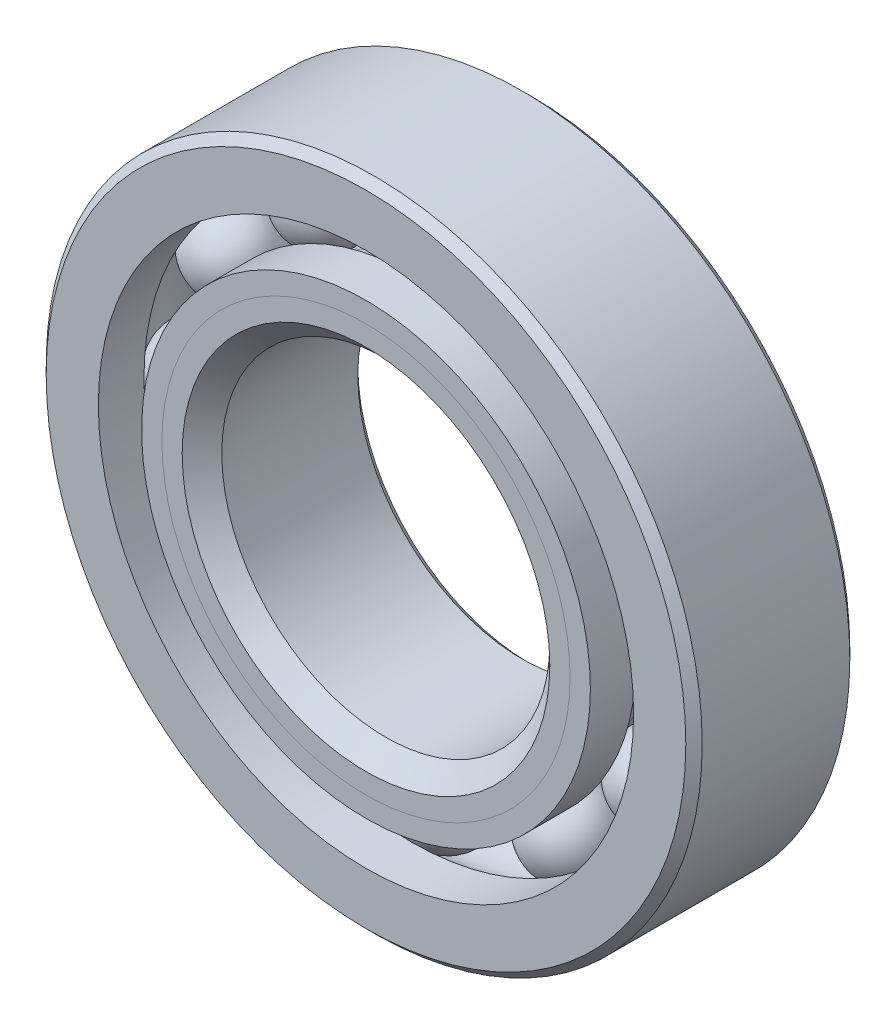
from build123d import *

# Parameters (mm, degrees)
CIRPATTERN1_COUNT = 12


with BuildPart() as part:
    # Sketch1 → Revolve1 (revolve)
    with BuildSketch(Plane(origin=(0, 0, 0), x_dir=(0, 0, -1), z_dir=(1, 0, 0))):
        with BuildLine():
            Line((1.42875, 6.35), (-1.42875, 6.35))
            Line((-1.42875, 6.35), (-1.5875, 6.19125))
            Line((-1.5875, 6.19125), (-1.5875, 5.181181319))
            Line((-1.5875, 5.181181319), (-0.705555556, 5.181181319))
            ThreePointArc((-0.705555556, 5.181181319), (0, 5.582928357), (0.705555556, 5.181181319))
            Line((0.705555556, 5.181181319), (1.5875, 5.181181319))
            Line((1.5875, 5.181181319), (1.5875, 6.19125))
            Line((1.5875, 6.19125), (1.42875, 6.35))
        make_face()
    revolve(axis=Axis((0, 0, 1.5875), (0, 0, -1)))


with BuildPart() as body_2:
    # Sketch2 → Revolve2 (revolve)
    with BuildSketch(Plane(origin=(0, 0, 0), x_dir=(0, 0, -1), z_dir=(1, 0, 0))):
        with BuildLine():
            Line((-1.5875, 4.343818681), (-0.705555556, 4.343818681))
            ThreePointArc((-0.705555556, 4.343818681), (-0.405958534, 4.049548138), (0, 3.942071643))
            Line((0, 3.942071643), (0, 3.558535822))
            Line((0, 3.558535822), (-1.19485857, 3.558535822))
            Line((-1.19485857, 3.558535822), (-1.5875, 3.951177251))
            Line((-1.5875, 3.951177251), (-1.5875, 4.343818681))
        make_face()
    revolve(axis=Axis((0, 0, 1.5875), (0, 0, -1)))


with BuildPart() as body_3:
    # Sketch3 → Revolve3 (revolve)
    with BuildSketch(Plane(origin=(0, 0, 0), x_dir=(0, 0, -1), z_dir=(1, 0, 0))):
        with BuildLine():
            Line((-1.5875, 3.951177251), (-1.19485857, 3.558535822))
            Line((-1.19485857, 3.558535822), (0, 3.558535822))
            Line((0, 3.558535822), (0, 3.942071643))
            ThreePointArc((0, 3.942071643), (0.405958534, 4.049548138), (0.705555556, 4.343818681))
            Line((0.705555556, 4.343818681), (1.5875, 4.343818681))
            Line((1.5875, 4.343818681), (1.5875, 3.33375))
            Line((1.5875, 3.33375), (1.42875, 3.175))
            Line((1.42875, 3.175), (-1.203964178, 3.175))
            Line((-1.203964178, 3.175), (-1.5875, 3.558535822))
            Line((-1.5875, 3.558535822), (-1.5875, 3.951177251))
        make_face()
    revolve(axis=Axis((0, 0, 1.5875), (0, 0, -1)))


with BuildPart() as body_4:
    # Sketch4 → Revolve4 (revolve)
    with BuildSketch(Plane(origin=(0, 0, 0), x_dir=(0, 0, -1), z_dir=(1, 0, 0))):
        with BuildLine():
            Line((-0.820428357, 4.7625), (0.820428357, 4.7625))
            ThreePointArc((0.820428357, 4.7625), (0, 5.582928357), (-0.820428357, 4.7625))
        make_face()
    revolve(axis=Axis((0, 4.7625, 0.820428357), (0, 0, -1)))


with BuildPart() as cirpattern1_1:
    # CirPattern1: pattern copy
    add(body_4.part.rotate(Axis((0, 0, 0), (0, 0, 1)), 1 * 360 / CIRPATTERN1_COUNT))


with BuildPart() as cirpattern1_2:
    # CirPattern1: pattern copy
    add(body_4.part.rotate(Axis((0, 0, 0), (0, 0, 1)), 2 * 360 / CIRPATTERN1_COUNT))


with BuildPart() as cirpattern1_3:
    # CirPattern1: pattern copy
    add(body_4.part.rotate(Axis((0, 0, 0), (0, 0, 1)), 3 * 360 / CIRPATTERN1_COUNT))


with BuildPart() as cirpattern1_4:
    # CirPattern1: pattern copy
    add(body_4.part.rotate(Axis((0, 0, 0), (0, 0, 1)), 4 * 360 / CIRPATTERN1_COUNT))


with BuildPart() as cirpattern1_5:
    # CirPattern1: pattern copy
    add(body_4.part.rotate(Axis((0, 0, 0), (0, 0, 1)), 5 * 360 / CIRPATTERN1_COUNT))


with BuildPart() as cirpattern1_6:
    # CirPattern1: pattern copy
    add(body_4.part.rotate(Axis((0, 0, 0), (0, 0, 1)), 6 * 360 / CIRPATTERN1_COUNT))


with BuildPart() as cirpattern1_7:
    # CirPattern1: pattern copy
    add(body_4.part.rotate(Axis((0, 0, 0), (0, 0, 1)), 7 * 360 / CIRPATTERN1_COUNT))


with BuildPart() as cirpattern1_8:
    # CirPattern1: pattern copy
    add(body_4.part.rotate(Axis((0, 0, 0), (0, 0, 1)), 8 * 360 / CIRPATTERN1_COUNT))


with BuildPart() as cirpattern1_9:
    # CirPattern1: pattern copy
    add(body_4.part.rotate(Axis((0, 0, 0), (0, 0, 1)), 9 * 360 / CIRPATTERN1_COUNT))


with BuildPart() as cirpattern1_10:
    # CirPattern1: pattern copy
    add(body_4.part.rotate(Axis((0, 0, 0), (0, 0, 1)), 10 * 360 / CIRPATTERN1_COUNT))


with BuildPart() as cirpattern1_11:
    # CirPattern1: pattern copy
    add(body_4.part.rotate(Axis((0, 0, 0), (0, 0, 1)), 11 * 360 / CIRPATTERN1_COUNT))


solid = Compound([part.part, body_2.part, body_3.part, body_4.part, cirpattern1_1.part, cirpattern1_2.part, cirpattern1_3.part, cirpattern1_4.part, cirpattern1_5.part, cirpattern1_6.part, cirpattern1_7.part, cirpattern1_8.part, cirpattern1_9.part, cirpattern1_10.part, cirpattern1_11.part])
